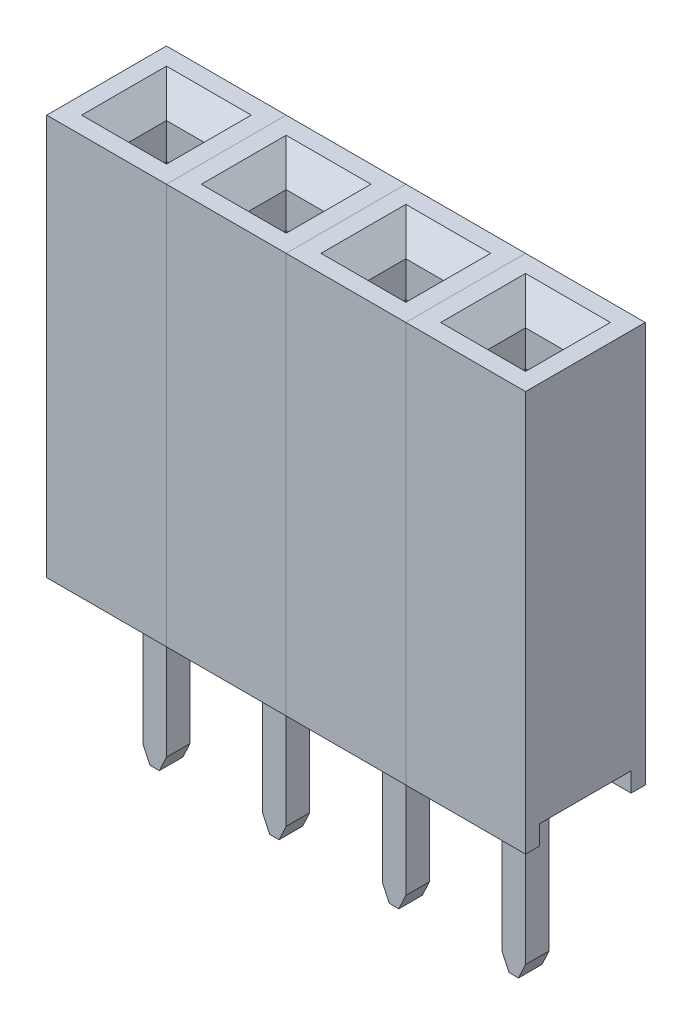
from build123d import *

# Parameters (mm, degrees)
SKETCH1_W               = 2.54
SKETCH1_H               = 8.5
BOSS_EXTRUDE1_DEPTH     = 1.27
SKETCH2_W               = 1.94
SKETCH2_H               = 0.410374384
CUT_EXTRUDE1_DEPTH      = 50
SKETCH4_W               = 0.8
SKETCH4_H               = 0.8
CUT_EXTRUDE2_DEPTH      = 1.5
CHAMFER1_SIZE           = 0.5
CUT_EXTRUDE3_DEPTH      = 3
CUT_EXTRUDE3_DEPTH_BACK = 3
SKETCH5_W               = 1.8
SKETCH5_H               = 1.8
BOSS_EXTRUDE4_DEPTH     = 0.85
BOSS_EXTRUDE5_DEPTH     = 0.25
LPATTERN1_COUNT         = 4
LPATTERN1_PITCH         = 2.54


with BuildPart() as part:
    # Sketch1 → Boss-Extrude1 (new, symmetric)
    with BuildSketch(Plane.XY):
        Rectangle(SKETCH1_W, SKETCH1_H)
    extrude(amount=BOSS_EXTRUDE1_DEPTH, both=True)

    # Sketch2 → Cut-Extrude1 (cut, symmetric)
    with BuildSketch(Plane(origin=(0, 0, 0), x_dir=(0, 0, -1), z_dir=(1, 0, 0))):
        with Locations((0, -4.044812808)):
            Rectangle(SKETCH2_W, SKETCH2_H)
    extrude(amount=CUT_EXTRUDE1_DEPTH, both=True, mode=Mode.SUBTRACT)

    # Sketch4 → Cut-Extrude2 (cut)
    with BuildSketch(Plane(origin=(0, 4.25, 0), x_dir=(1, 0, 0), z_dir=(0, 1, 0))):
        Rectangle(SKETCH4_W, SKETCH4_H)
    extrude(amount=-CUT_EXTRUDE2_DEPTH, mode=Mode.SUBTRACT)

    # Chamfer1
    chamfer1_edges = [part.edges().sort_by_distance(p)[0] for p in [
        (0, 4.25, -0.4),
        (-0.4, 4.25, 0),
        (0, 4.25, 0.4),
        (0.4, 4.25, 0),
    ]]
    chamfer(chamfer1_edges, length=CHAMFER1_SIZE)

    # Sketch5 → Cut-Extrude3 (cut, two sides: drawn at the far end of the back side and taken through both)
    with BuildSketch(Plane(origin=(0, 0, 0), x_dir=(1, 0, 0), z_dir=(0, 1, 0)).offset(-CUT_EXTRUDE3_DEPTH_BACK)):
        Rectangle(SKETCH5_W, SKETCH5_H)
    extrude(amount=CUT_EXTRUDE3_DEPTH + CUT_EXTRUDE3_DEPTH_BACK, mode=Mode.SUBTRACT)

    # Sketch9 → Boss-Extrude4 (add, symmetric)
    with BuildSketch(Plane.XY):
        with BuildLine():
            ThreePointArc((0.507505583, -1.97169351), (0.361743925, -2.312679398), (0, -2.394283131))
            ThreePointArc((0, -2.394283131), (-0.361743925, -2.312679398), (-0.507505583, -1.97169351))
            Line((-0.507505583, -1.97169351), (-0.280281264, 1.339289432))
            ThreePointArc((-0.280281264, 1.339289432), (-0.162585139, 1.576117793), (-0.413271806, 1.491878581))
            Line((-0.413271806, 1.491878581), (-0.602186386, -1.260876719))
            Line((-0.602186386, -1.260876719), (-0.852765845, -1.341648528))
            Line((-0.852765845, -1.341648528), (-0.852765845, -2.693306042))
            Line((-0.852765845, -2.693306042), (-0.280728289, -3.053320584))
            Line((-0.280728289, -3.053320584), (0.280728289, -3.053320584))
            Line((0.280728289, -3.053320584), (0.852765845, -2.693306042))
            Line((0.852765845, -2.693306042), (0.852765845, -1.341648528))
            Line((0.852765845, -1.341648528), (0.602186386, -1.260876719))
            Line((0.602186386, -1.260876719), (0.413271806, 1.491878581))
            ThreePointArc((0.413271806, 1.491878581), (0.162585139, 1.576117793), (0.280281264, 1.339289432))
            Line((0.280281264, 1.339289432), (0.507505583, -1.97169351))
        make_face()
    extrude(amount=BOSS_EXTRUDE4_DEPTH, both=True)

    # Sketch9_3 → Boss-Extrude5 (add, symmetric)
    with BuildSketch(Plane.XY):
        Polygon((0.25, -7.299491593), (0.25, -3.053320584), (-0.25, -3.053320584), (-0.25, -7.299491593), (-0.1, -7.621167632), (0.1, -7.621167632), align=None)
    extrude(amount=BOSS_EXTRUDE5_DEPTH, both=True)


with BuildPart() as lpattern1_1:
    # LPattern1: pattern copy
    add(part.part.moved(Location(Vector(-1, 0, 0) * (1 * LPATTERN1_PITCH))))


with BuildPart() as lpattern1_2:
    # LPattern1: pattern copy
    add(part.part.moved(Location(Vector(-1, 0, 0) * (2 * LPATTERN1_PITCH))))


with BuildPart() as lpattern1_3:
    # LPattern1: pattern copy
    add(part.part.moved(Location(Vector(-1, 0, 0) * (3 * LPATTERN1_PITCH))))


solid = Compound([part.part, lpattern1_1.part, lpattern1_2.part, lpattern1_3.part])
